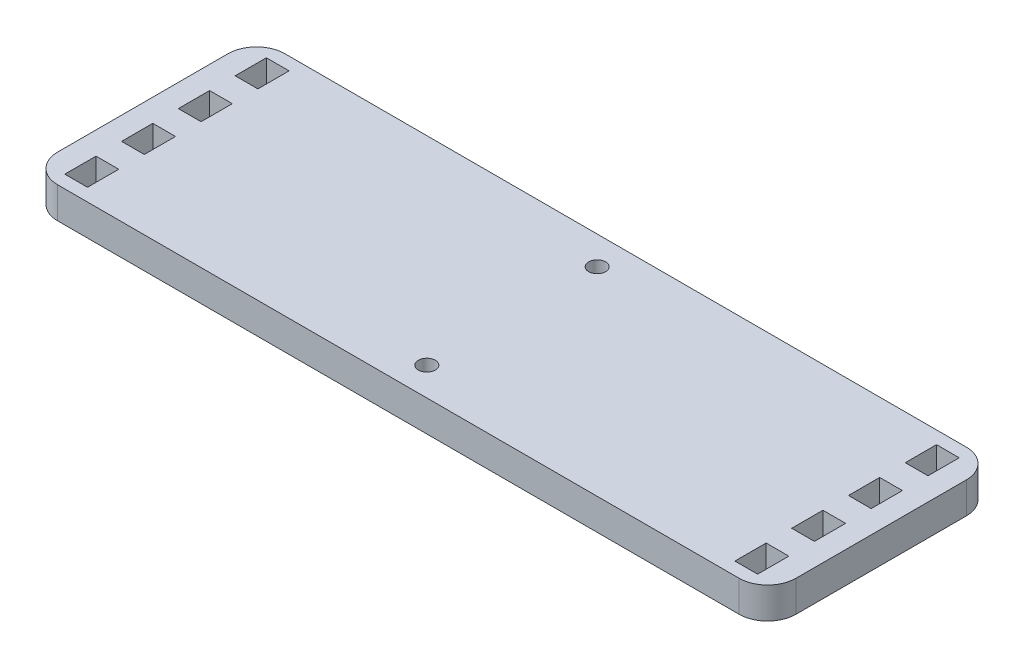
from build123d import *

# Parameters (mm, degrees)
SKETCH1_W           = 130
SKETCH1_H           = 40
SKETCH1_R           = 1.5
BOSS_EXTRUDE1_DEPTH = 5.5
SKETCH2_W           = 4
SKETCH2_H           = 5.5
CUT_EXTRUDE1_DEPTH  = 6.5
FILLET1_R           = 5


with BuildPart() as part:
    # Sketch1 → Boss-Extrude1 (new body)
    with BuildSketch(Plane(origin=(0, 0, 0), x_dir=(1, 0, 0), z_dir=(0, 1, 0))):
        Rectangle(SKETCH1_W, SKETCH1_H)
        with Locations((0, 15)):
            Circle(SKETCH1_R, mode=Mode.SUBTRACT)
        with Locations((0, -15)):
            Circle(SKETCH1_R, mode=Mode.SUBTRACT)
    extrude(amount=BOSS_EXTRUDE1_DEPTH)

    # Sketch2 → Cut-Extrude1 (cut, through all)
    with BuildSketch(Plane(origin=(0, 5.5, 0), x_dir=(1, 0, 0), z_dir=(0, 1, 0))):
        with Locations((-59, 5)):
            Rectangle(SKETCH2_W, SKETCH2_H)
        with Locations((-59, 15)):
            Rectangle(SKETCH2_W, SKETCH2_H)
        with Locations((-59, -5)):
            Rectangle(SKETCH2_W, SKETCH2_H)
        with Locations((-59, -15)):
            Rectangle(SKETCH2_W, SKETCH2_H)
        with Locations((59, -15)):
            Rectangle(SKETCH2_W, SKETCH2_H)
        with Locations((59, 15)):
            Rectangle(SKETCH2_W, SKETCH2_H)
        with Locations((59, -5)):
            Rectangle(SKETCH2_W, SKETCH2_H)
        with Locations((59, 5)):
            Rectangle(SKETCH2_W, SKETCH2_H)
    extrude(amount=-CUT_EXTRUDE1_DEPTH, mode=Mode.SUBTRACT)

    # Fillet1
    fillet1_edges = [part.edges().sort_by_distance(p)[0] for p in [
        (-65, 2.75, -20),
        (65, 2.75, -20),
        (65, 2.75, 20),
        (-65, 2.75, 20),
    ]]
    fillet(fillet1_edges, radius=FILLET1_R)


solid = part.part
